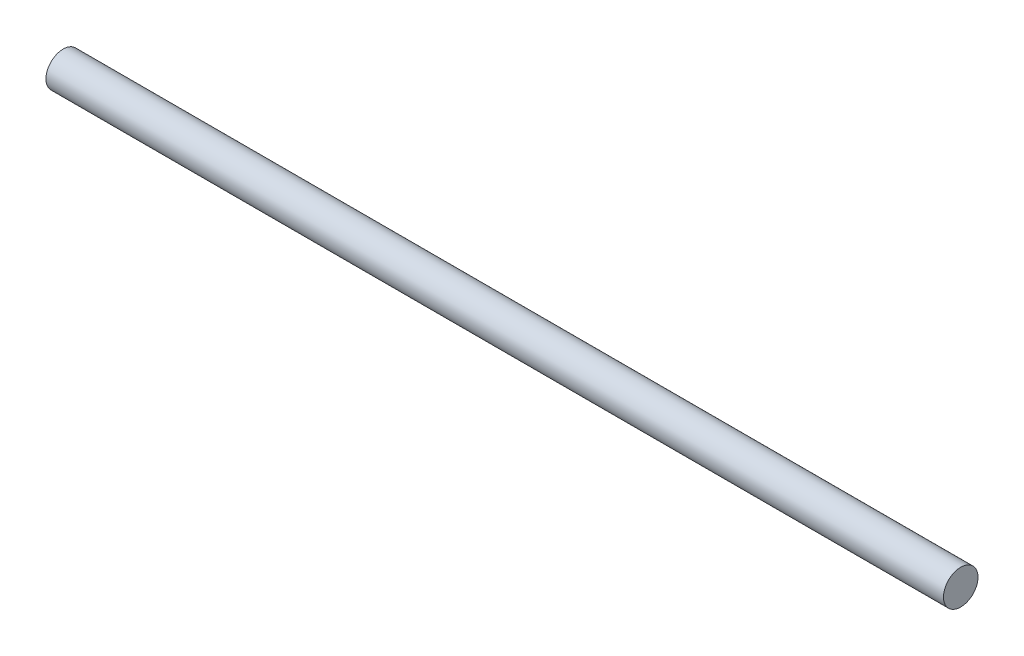
from build123d import *

# Parameters (mm, degrees)
SKETCH1_R           = 10
BOSS_EXTRUDE1_DEPTH = 520


with BuildPart() as part:
    # Sketch1 → Boss-Extrude1 (new body)
    with BuildSketch(Plane(origin=(0, 0, 0), x_dir=(0, 0, -1), z_dir=(1, 0, 0))):
        Circle(SKETCH1_R)
    extrude(amount=BOSS_EXTRUDE1_DEPTH)


solid = part.part
